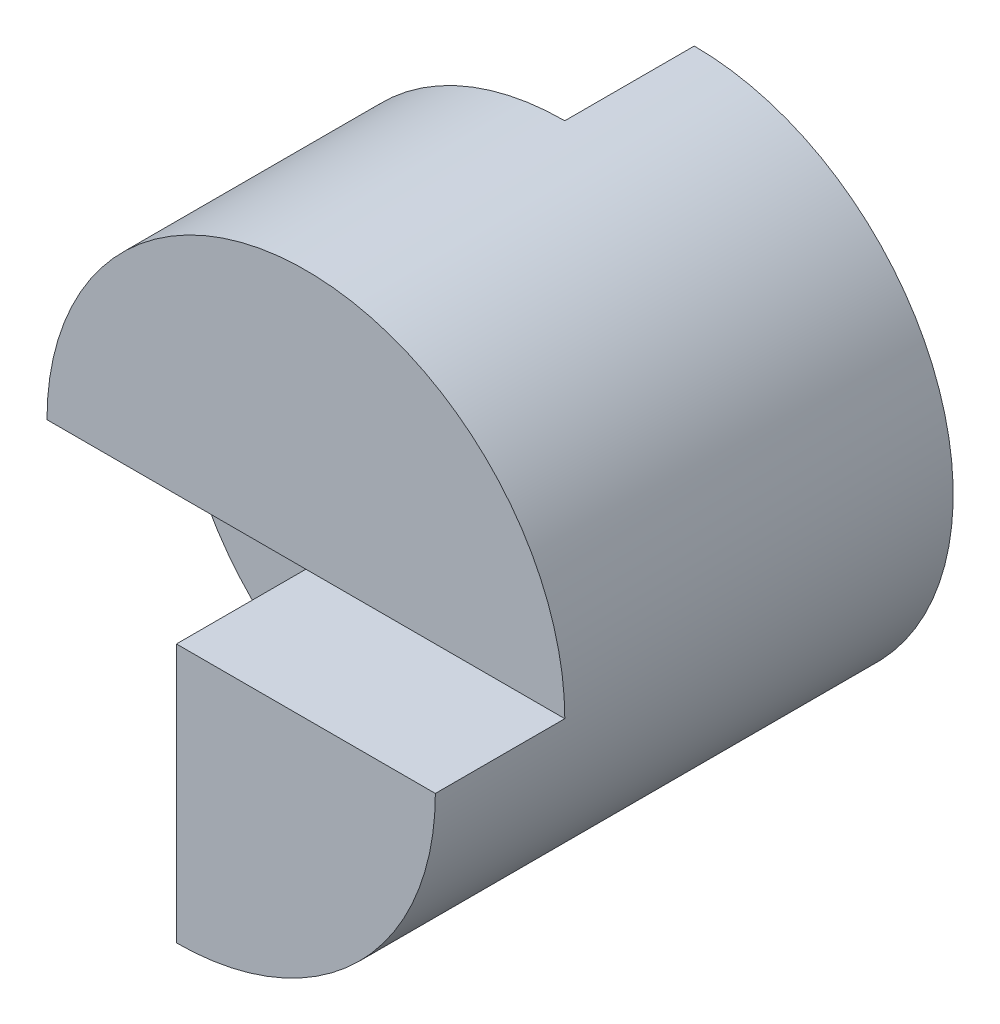
from build123d import *

# Parameters (mm, degrees)
SKETCH1_R           = 20
BOSS_EXTRUDE1_DEPTH = 40
SKETCH2_W           = 20
SKETCH2_H           = 10
CUT_EXTRUDE1_DEPTH  = 40
CUT_EXTRUDE2_DEPTH  = 10
CUT_EXTRUDE3_DEPTH  = 20
SKETCH5_W           = 20
SKETCH5_H           = 10
CUT_EXTRUDE4_DEPTH  = 20


with BuildPart() as part:
    # Sketch1 → Boss-Extrude1 (new body)
    with BuildSketch(Plane.XY):
        Circle(SKETCH1_R)
    extrude(amount=BOSS_EXTRUDE1_DEPTH)

    # Sketch2 → Cut-Extrude1 (cut)
    with BuildSketch(Plane(origin=(0, 0, 0), x_dir=(1, 0, 0), z_dir=(0, 1, 0))):
        with Locations((-10, -35)):
            Rectangle(SKETCH2_W, SKETCH2_H)
        with Locations((-10, -5)):
            Rectangle(SKETCH2_W, SKETCH2_H)
    extrude(amount=CUT_EXTRUDE1_DEPTH, mode=Mode.SUBTRACT)

    # Sketch3 → Cut-Extrude2 (cut)
    with BuildSketch(Plane.XY.offset(40)):
        with BuildLine():
            Line((0, 20), (0, 0))
            Line((0, 0), (20, 0))
            ThreePointArc((20, 0), (14.142135624, 14.142135624), (0, 20))
        make_face()
    extrude(amount=-CUT_EXTRUDE2_DEPTH, mode=Mode.SUBTRACT)

    # Sketch4 → Cut-Extrude3 (cut)
    with BuildSketch(Plane.XY.offset(40)):
        with BuildLine():
            Line((-20, 0), (0, 0))
            Line((0, 0), (0, -20))
            ThreePointArc((0, -20), (-14.142135624, -14.142135624), (-20, 0))
        make_face()
    extrude(amount=-CUT_EXTRUDE3_DEPTH, mode=Mode.SUBTRACT)

    # Sketch5 → Cut-Extrude4 (cut)
    with BuildSketch(Plane(origin=(0, 0, 0), x_dir=(1, 0, 0), z_dir=(0, 1, 0))):
        with Locations((-10, -5)):
            Rectangle(SKETCH5_W, SKETCH5_H)
    extrude(amount=-CUT_EXTRUDE4_DEPTH, mode=Mode.SUBTRACT)


solid = part.part
